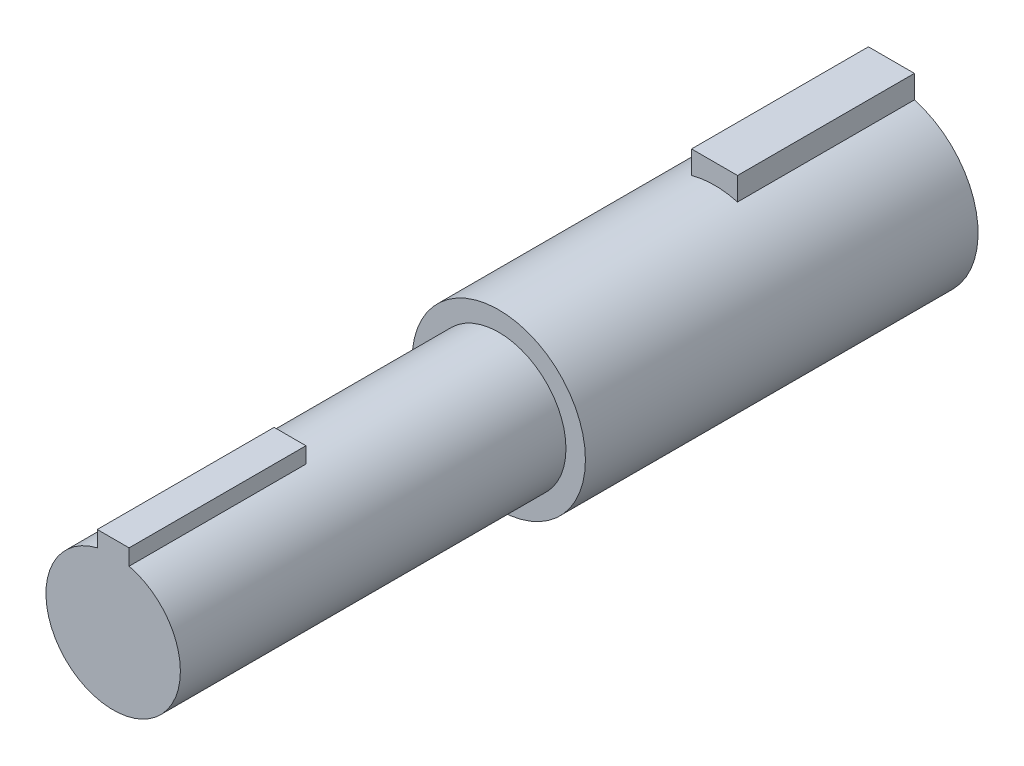
from build123d import *

# Parameters (mm, degrees)
SKETCH1_R                = 6.223
BOSS_EXTRUDE1_DEPTH      = 28.194
SKETCH2_R                = 4.826
BOSS_EXTRUDE2_DEPTH      = 27.686
BOSS_EXTRUDE2_DEPTH_BACK = 5.08
SKETCH3_W                = 2.286
SKETCH3_H                = 2.286
BOSS_EXTRUDE3_DEPTH      = 12.7
SKETCH4_W                = 3.302
SKETCH4_H                = 3.302
BOSS_EXTRUDE4_DEPTH      = 12.7


with BuildPart() as part:
    # Sketch1 → Boss-Extrude1 (new body)
    with BuildSketch(Plane.XY):
        Circle(SKETCH1_R)
    extrude(amount=BOSS_EXTRUDE1_DEPTH)

    # Sketch2 → Boss-Extrude2 (add, two sides)
    with BuildSketch(Plane.XY.offset(28.194)) as boss_extrude2_sk:
        Circle(SKETCH2_R)
    extrude(amount=BOSS_EXTRUDE2_DEPTH)
    extrude(boss_extrude2_sk.sketch, amount=-BOSS_EXTRUDE2_DEPTH_BACK)

    # Sketch3 → Boss-Extrude3 (add)
    with BuildSketch(Plane.XY.offset(55.88)):
        with Locations((0, 4.688691395)):
            Rectangle(SKETCH3_W, SKETCH3_H)
    extrude(amount=-BOSS_EXTRUDE3_DEPTH)

    # Sketch4 → Boss-Extrude4 (add)
    with BuildSketch(Plane(origin=(0, 0, 0), x_dir=(-1, 0, 0), z_dir=(0, 0, -1))):
        with Locations((0, 5.999994)):
            Rectangle(SKETCH4_W, SKETCH4_H)
    extrude(amount=-BOSS_EXTRUDE4_DEPTH)


solid = part.part
